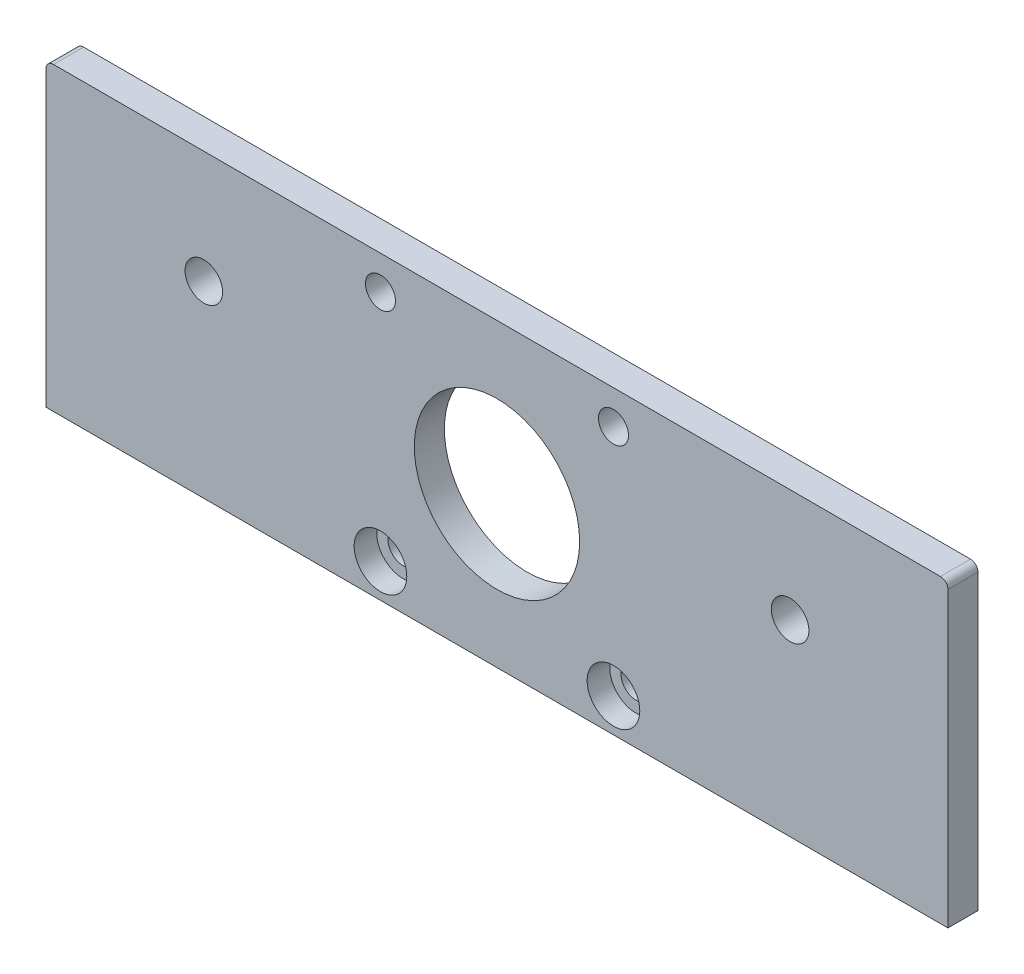
from build123d import *

# Parameters (mm, degrees)
SKETCH1_W           = 120
SKETCH1_H           = 40
SKETCH1_R           = 2.5
SKETCH1_R_2         = 11
SKETCH1_R_3         = 2
BOSS_EXTRUDE1_DEPTH = 4
FILLET1_R           = 1
SKETCH2_R           = 3.5
CUT_EXTRUDE1_DEPTH  = 3


with BuildPart() as part:
    # Sketch1 → Boss-Extrude1 (new body)
    with BuildSketch(Plane.XY):
        with Locations((60, 20)):
            Rectangle(SKETCH1_W, SKETCH1_H)
        with Locations((21, 25)):
            Circle(SKETCH1_R, mode=Mode.SUBTRACT)
        with Locations((99, 25)):
            Circle(SKETCH1_R, mode=Mode.SUBTRACT)
        with Locations((60, 20)):
            Circle(SKETCH1_R_2, mode=Mode.SUBTRACT)
        with Locations((75.5, 35.5)):
            Circle(SKETCH1_R_3, mode=Mode.SUBTRACT)
        with Locations((75.5, 4.5)):
            Circle(SKETCH1_R_3, mode=Mode.SUBTRACT)
        with Locations((44.5, 4.5)):
            Circle(SKETCH1_R_3, mode=Mode.SUBTRACT)
        with Locations((44.5, 35.5)):
            Circle(SKETCH1_R_3, mode=Mode.SUBTRACT)
    extrude(amount=BOSS_EXTRUDE1_DEPTH)

    # Fillet1
    fillet1_edges = [part.edges().sort_by_distance(p)[0] for p in [
        (0, 40, 2),
        (120, 40, 2),
    ]]
    fillet(fillet1_edges, radius=FILLET1_R)

    # Sketch2 → Cut-Extrude1 (cut)
    with BuildSketch(Plane.XY.offset(4)):
        with Locations((44.5, 4.5)):
            Circle(SKETCH2_R)
        with Locations((75.5, 4.5)):
            Circle(SKETCH2_R)
    extrude(amount=-CUT_EXTRUDE1_DEPTH, mode=Mode.SUBTRACT)


solid = part.part
